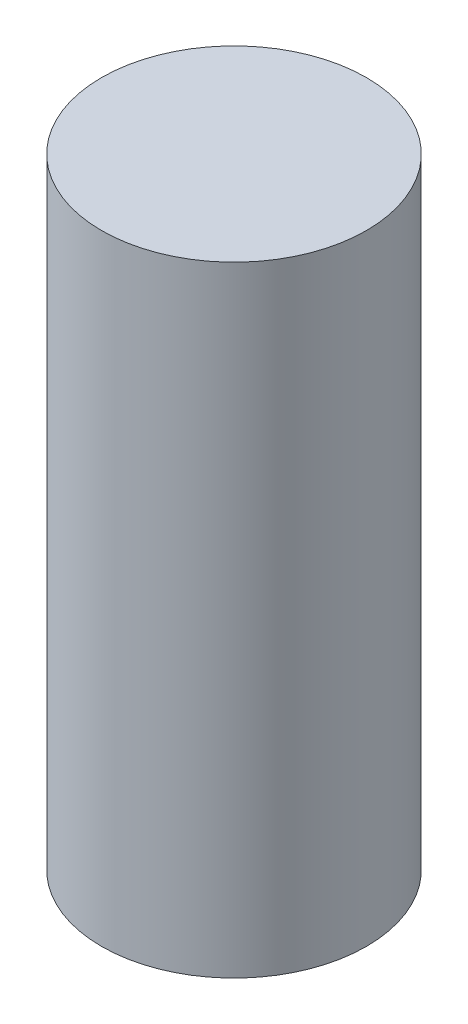
from build123d import *

# Parameters (mm, degrees)
SKETCH1_R           = 5
BOSS_EXTRUDE1_DEPTH = 23.4
SKETCH4_R           = 2.45
CUT_EXTRUDE2_DEPTH  = 4.69


with BuildPart() as part:
    # Sketch1 → Boss-Extrude1 (new body)
    with BuildSketch(Plane(origin=(0, 0, 0), x_dir=(1, 0, 0), z_dir=(0, 1, 0))):
        Circle(SKETCH1_R)
    extrude(amount=BOSS_EXTRUDE1_DEPTH)

    # Sketch4 → Cut-Extrude2 (cut)
    with BuildSketch(Plane(origin=(0, 0, 0), x_dir=(-1, 0, 0), z_dir=(0, -1, 0))):
        Circle(SKETCH4_R)
    extrude(amount=-CUT_EXTRUDE2_DEPTH, mode=Mode.SUBTRACT)


solid = part.part
